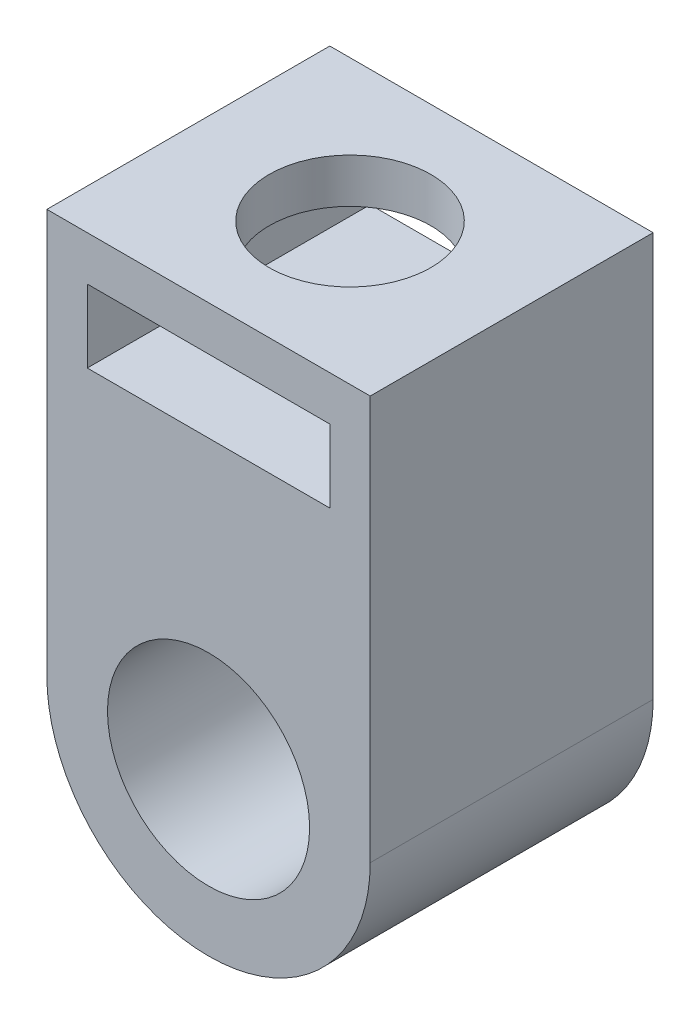
from build123d import *

# Parameters (mm, degrees)
SKETCH2_R           = 2.5
BOSS_EXTRUDE1_DEPTH = 7
SKETCH3_W           = 6
SKETCH3_H           = 1.8
CUT_EXTRUDE1_DEPTH  = 7
SKETCH4_R           = 2
CUT_EXTRUDE2_DEPTH  = 2


with BuildPart() as part:
    # Sketch2 → Boss-Extrude1 (new body)
    with BuildSketch(Plane.XY):
        with BuildLine():
            Line((-4, 0), (-4, 10))
            Line((-4, 10), (4, 10))
            Line((4, 10), (4, 0))
            ThreePointArc((4, 0), (0, -4), (-4, 0))
        make_face()
        Circle(SKETCH2_R, mode=Mode.SUBTRACT)
    extrude(amount=BOSS_EXTRUDE1_DEPTH)

    # Sketch3 → Cut-Extrude1 (cut)
    with BuildSketch(Plane.XY.offset(7)):
        with Locations((0, 8)):
            Rectangle(SKETCH3_W, SKETCH3_H)
    extrude(amount=-CUT_EXTRUDE1_DEPTH, mode=Mode.SUBTRACT)

    # Sketch4 → Cut-Extrude2 (cut)
    with BuildSketch(Plane(origin=(0, 10, 0), x_dir=(1, 0, 0), z_dir=(0, 1, 0))):
        with Locations((0, -3.5)):
            Circle(SKETCH4_R)
    extrude(amount=-CUT_EXTRUDE2_DEPTH, mode=Mode.SUBTRACT)


solid = part.part
